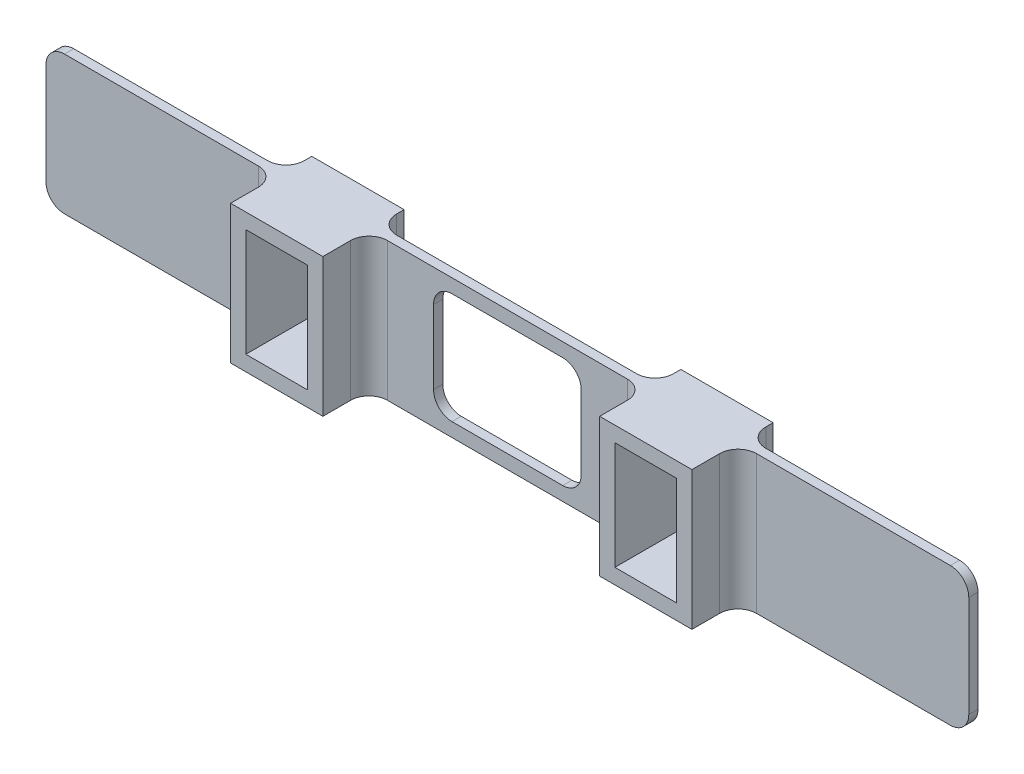
from build123d import *

# Parameters (mm, degrees)
SKETCH1_W           = 500
SKETCH1_H           = 75
BOSS_EXTRUDE1_DEPTH = 5
SKETCH2_W           = 33.5
SKETCH2_H           = 58.5
SKETCH2_H_2         = 58.503478076
CUT_EXTRUDE1_DEPTH  = 5
SKETCH3_W           = 50
SKETCH3_H           = 75
SKETCH3_W_2         = 33.5
SKETCH3_H_2         = 58.5
SKETCH3_H_3         = 58.503478076
BOSS_EXTRUDE4_DEPTH = 25
SKETCH5_W           = 50
SKETCH5_H           = 75
SKETCH5_W_2         = 33.5
SKETCH5_H_2         = 58.5
SKETCH5_H_3         = 58.503478076
BOSS_EXTRUDE5_DEPTH = 14
FILLET1_R           = 10
FILLET2_R           = 10
SKETCH6_W           = 80
SKETCH6_H           = 60
CUT_EXTRUDE3_DEPTH  = 380
FILLET3_R           = 10


with BuildPart() as part:
    # Sketch1 → Boss-Extrude1 (new body)
    with BuildSketch(Plane.XY):
        Rectangle(SKETCH1_W, SKETCH1_H)
    extrude(amount=BOSS_EXTRUDE1_DEPTH)

    # Sketch2 → Cut-Extrude1 (cut)
    with BuildSketch(Plane.XY.offset(5)):
        with Locations((-99.970770454, 0)):
            Rectangle(SKETCH2_W, SKETCH2_H)
        with Locations((100, 0)):
            Rectangle(SKETCH2_W, SKETCH2_H_2)
    extrude(amount=-CUT_EXTRUDE1_DEPTH, mode=Mode.SUBTRACT)

    # Sketch3 → Boss-Extrude4 (add)
    with BuildSketch(Plane.XY.offset(5)):
        with Locations((-99.970770454, 0)):
            Rectangle(SKETCH3_W, SKETCH3_H)
        with Locations((-99.970770454, 0)):
            Rectangle(SKETCH3_W_2, SKETCH3_H_2, mode=Mode.SUBTRACT)
        with Locations((100, 0)):
            Rectangle(SKETCH3_W, SKETCH3_H)
        with Locations((100, 0)):
            Rectangle(SKETCH3_W_2, SKETCH3_H_3, mode=Mode.SUBTRACT)
    extrude(amount=BOSS_EXTRUDE4_DEPTH)

    # Sketch5 → Boss-Extrude5 (add)
    with BuildSketch(Plane(origin=(0, 0, 0), x_dir=(-1, 0, 0), z_dir=(0, 0, -1))):
        with Locations((99.970770454, 0)):
            Rectangle(SKETCH5_W, SKETCH5_H)
        with Locations((99.970770454, 0)):
            Rectangle(SKETCH5_W_2, SKETCH5_H_2, mode=Mode.SUBTRACT)
        with Locations((-100, 0)):
            Rectangle(SKETCH5_W, SKETCH5_H)
        with Locations((-100, 0)):
            Rectangle(SKETCH5_W_2, SKETCH5_H_3, mode=Mode.SUBTRACT)
    extrude(amount=BOSS_EXTRUDE5_DEPTH)

    # Fillet1
    fillet1_edges = [part.edges().sort_by_distance(p)[0] for p in [
        (75, 0, 0),
        (125, 0, 0),
        (-74.970770454, 0, 5),
        (-124.970770454, 0, 5),
        (125, 0, 5),
        (75, 0, 5),
        (250, -37.5, 2.5),
        (-250, -37.5, 2.5),
        (-250, 37.5, 2.5),
        (250, 37.5, 2.5),
        (-74.970770454, 0, 0),
    ]]
    fillet(fillet1_edges, radius=FILLET1_R)

    # Fillet2
    fillet2_edges = [part.edges().sort_by_distance(p)[0] for p in [
        (-124.970770454, 0, 0),
    ]]
    fillet(fillet2_edges, radius=FILLET2_R)

    # Sketch6 → Cut-Extrude3 (cut)
    with BuildSketch(Plane.XY.offset(5)):
        Rectangle(SKETCH6_W, SKETCH6_H)
    extrude(amount=-CUT_EXTRUDE3_DEPTH, mode=Mode.SUBTRACT)

    # Fillet3
    fillet3_edges = [part.edges().sort_by_distance(p)[0] for p in [
        (40, 30, 2.5),
        (40, -30, 2.5),
        (-40, -30, 2.5),
        (-40, 30, 2.5),
    ]]
    fillet(fillet3_edges, radius=FILLET3_R)


solid = part.part
